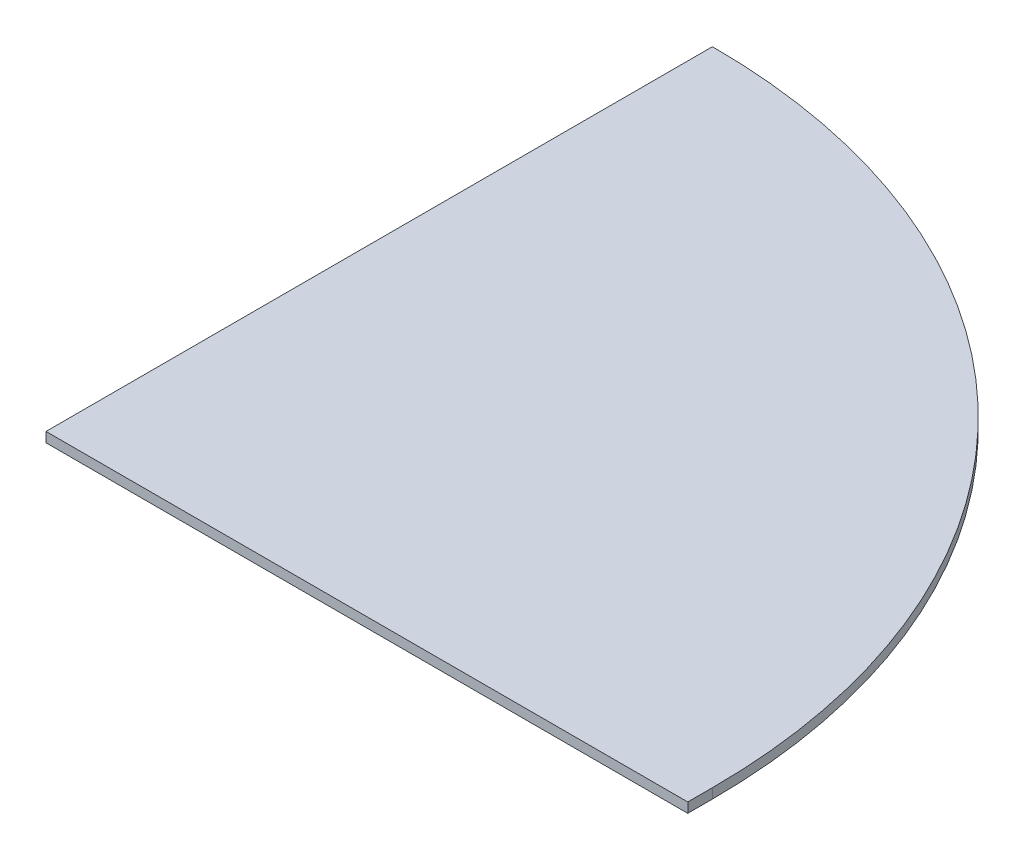
from build123d import *

# Parameters (mm, degrees)
BOSS_EXTRUDE1_DEPTH = 10.16


with BuildPart() as part:
    # Sketch2 → Boss-Extrude1 (new body)
    with BuildSketch(Plane(origin=(0, 0, 0), x_dir=(1, 0, 0), z_dir=(0, 1, 0))):
        with BuildLine():
            Line((0, 660.4), (0, -25.4))
            Line((0, -25.4), (660.4, -25.4))
            Line((660.4, -25.4), (660.4, 0))
            ThreePointArc((660.4, 0), (466.973318296, 466.973318296), (0, 660.4))
        make_face()
    extrude(amount=BOSS_EXTRUDE1_DEPTH)


solid = part.part
